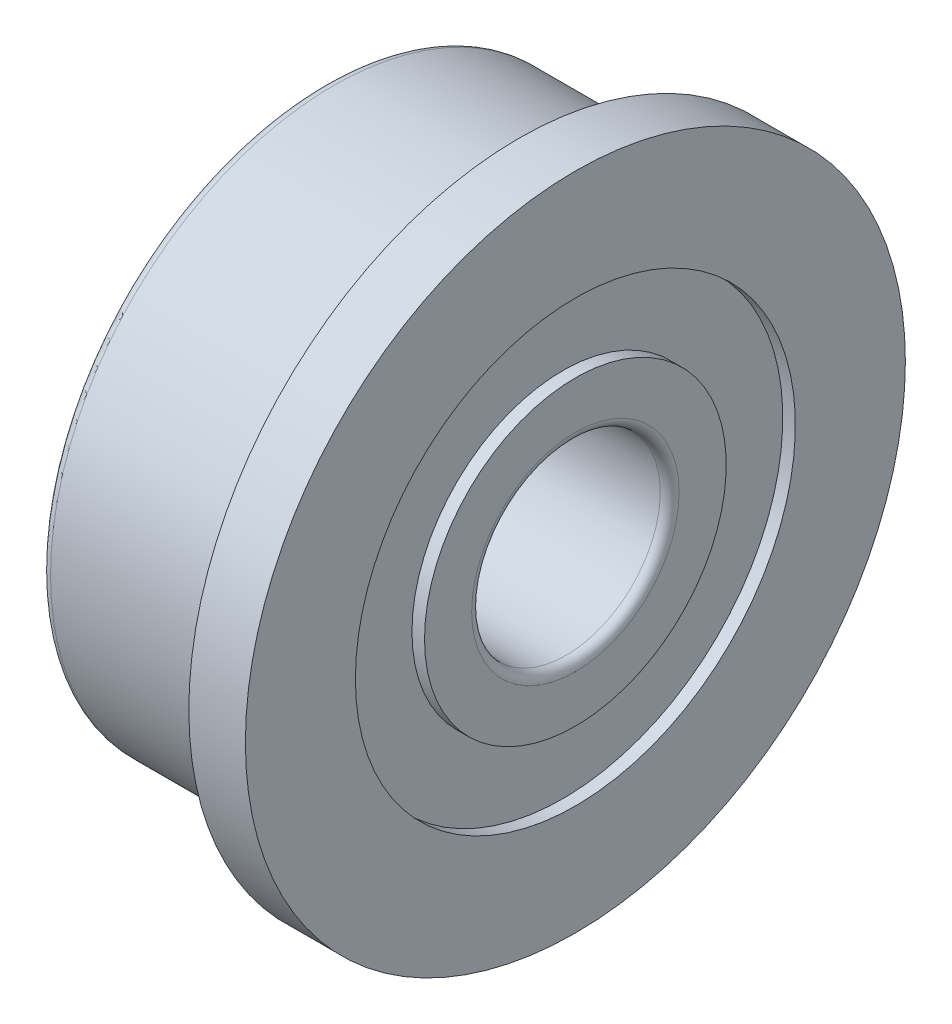
from build123d import *

# Parameters (mm, degrees)
FILLET1_R = 0.15


with BuildPart() as part:
    # Sketch1 → Revolve1 (revolve)
    with BuildSketch(Plane.XY):
        with BuildLine():
            Line((0, 4.7), (0, 5.25))
            Line((0, 5.25), (0.9, 5.25))
            Line((0.9, 5.25), (0.9, 3.5))
            Line((0.9, 3.5), (0.7, 3.5))
            Line((0.7, 3.5), (0.7, 2.4))
            Line((0.7, 2.4), (0.9, 2.4))
            Line((0.9, 2.4), (0.9, 1.5))
            Line((0.9, 1.5), (-3.1, 1.5))
            Line((-3.1, 1.5), (-3.1, 2.4))
            Line((-3.1, 2.4), (-2.9, 2.4))
            Line((-2.9, 2.4), (-2.9, 3.5))
            Line((-2.9, 3.5), (-3.1, 3.5))
            Line((-3.1, 3.5), (-3.1, 4.5))
            Line((-3.1, 4.5), (-0.2, 4.5))
            ThreePointArc((-0.2, 4.5), (0.141421356, 4.358578644), (0, 4.7))
        make_face()
    revolve(axis=Axis((-3.1, 0, 0), (1, 0, 0)))

    # Fillet1
    fillet1_edges = [part.edges().sort_by_distance(p)[0] for p in [
        (0.9, -1.5, 0),
        (-3.1, -1.5, 0),
        (-3.1, -4.5, 0),
    ]]
    fillet(fillet1_edges, radius=FILLET1_R)


solid = part.part
